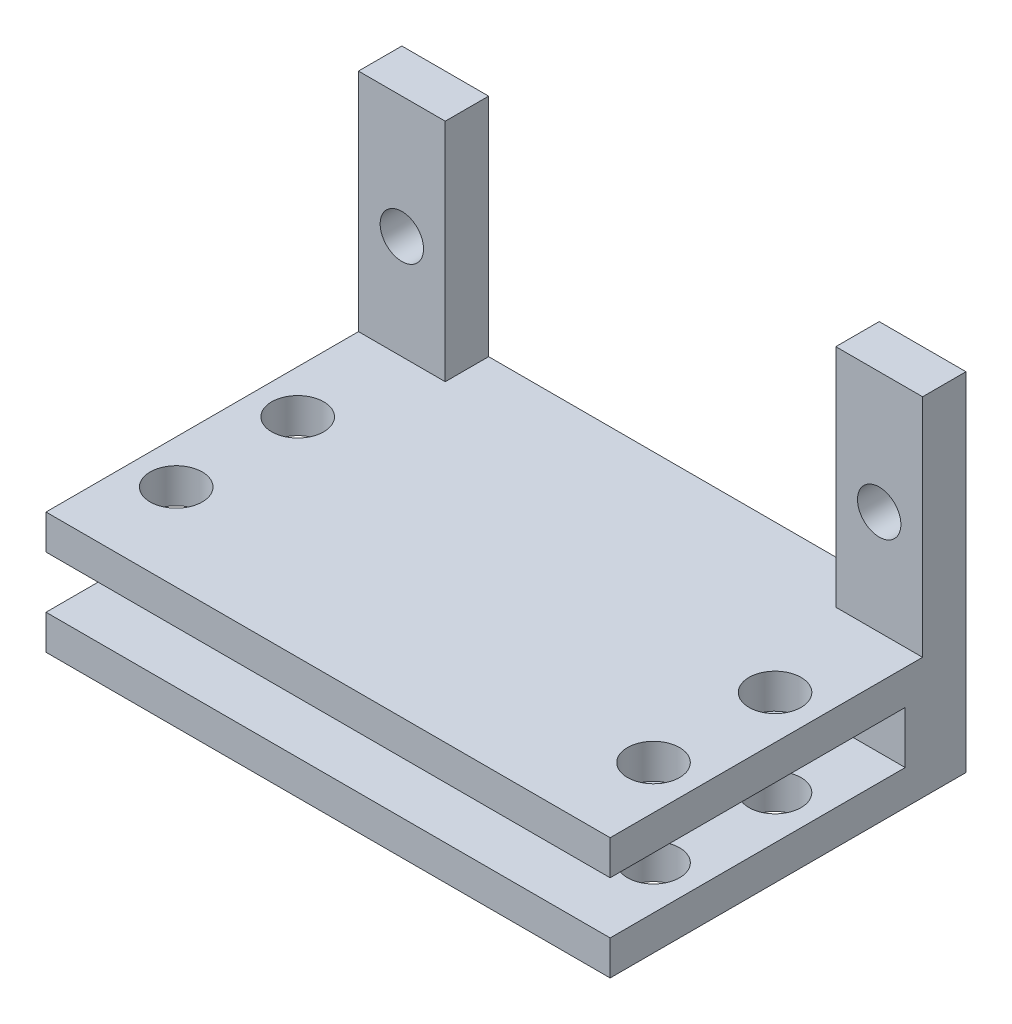
from build123d import *

# Parameters (mm, degrees)
SKETCH1_W               = 5
SKETCH1_H               = 13
SKETCH1_R               = 1.25
BOSS_EXTRUDE1_DEPTH     = 2.5
BOSS_EXTRUDE1_2_DEPTH   = 2.5
SKETCH1_5_W             = 32.5
SKETCH1_5_H             = 2
BOSS_EXTRUDE2_DEPTH     = 20.5
SKETCH1_6_W             = 32.5
SKETCH1_6_H             = 3
BOSS_EXTRUDE3_DEPTH     = 3.5
CUT_EXTRUDE2_DEPTH      = 30.211513141
CUT_EXTRUDE2_DEPTH_BACK = 30.211513141
SKETCH2_R               = 1.5


with BuildPart() as part:
    # Sketch1 → Boss-Extrude1 (new body)
    with BuildSketch(Plane.XY):
        with Locations((-13.75, 6.5)):
            Rectangle(SKETCH1_W, SKETCH1_H)
        with Locations((-13.75, 6)):
            Circle(SKETCH1_R, mode=Mode.SUBTRACT)
    extrude(amount=BOSS_EXTRUDE1_DEPTH)



with BuildPart() as body_2:
    # Sketch1 → Boss-Extrude1 2 (new body)
    with BuildSketch(Plane.XY):
        with Locations((13.75, 6.5)):
            Rectangle(SKETCH1_W, SKETCH1_H)
        with Locations((13.75, 6)):
            Circle(SKETCH1_R, mode=Mode.SUBTRACT)
    extrude(amount=BOSS_EXTRUDE1_2_DEPTH)


with BuildPart() as part_1:
    add(part.part)

    add(body_2.part)  # Boss-Extrude2 merges body 2
    # Sketch1_5 → Boss-Extrude2 (add)
    with BuildSketch(Plane.XY):
        with Locations((0, -1)):
            Rectangle(SKETCH1_5_W, SKETCH1_5_H)
        with Locations((0, -6)):
            Rectangle(SKETCH1_5_W, SKETCH1_5_H)
    extrude(amount=BOSS_EXTRUDE2_DEPTH)

    # Sketch1_6 → Boss-Extrude3 (add)
    with BuildSketch(Plane.XY):
        with Locations((0, -3.5)):
            Rectangle(SKETCH1_6_W, SKETCH1_6_H)
    extrude(amount=BOSS_EXTRUDE3_DEPTH)

    # Sketch2 → Cut-Extrude2 (cut, two sides: drawn at the far end of the back side and taken through both)
    with BuildSketch(Plane(origin=(0, 0, 0), x_dir=(1, 0, 0), z_dir=(0, 1, 0)).offset(-CUT_EXTRUDE2_DEPTH_BACK)):
        with Locations((13.75, -8.5)):
            Circle(SKETCH2_R)
        with Locations((13.75, -15.5)):
            Circle(SKETCH2_R)
        with Locations((-13.75, -15.5)):
            Circle(SKETCH2_R)
        with Locations((-13.75, -8.5)):
            Circle(SKETCH2_R)
    extrude(amount=CUT_EXTRUDE2_DEPTH + CUT_EXTRUDE2_DEPTH_BACK, mode=Mode.SUBTRACT)


solid = part_1.part
